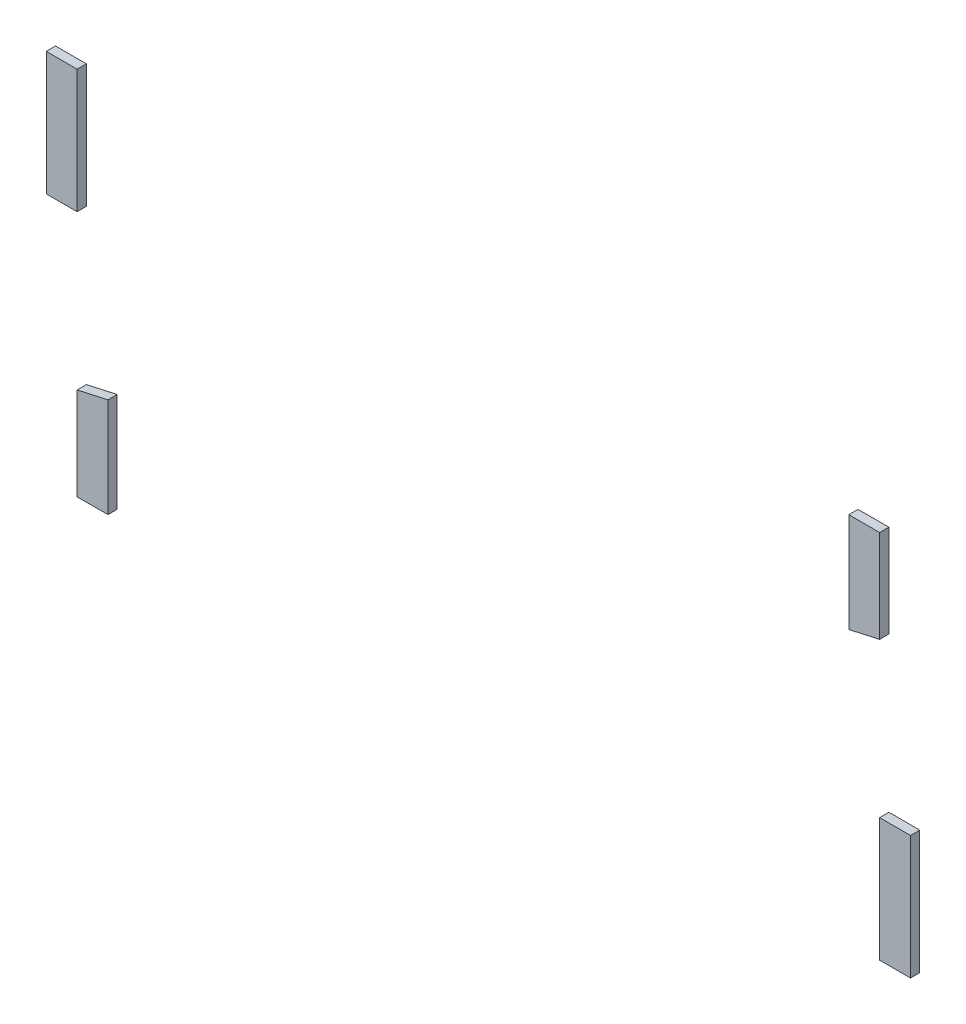
from build123d import *

# Parameters (mm, degrees)
SKETCH1_W             = 2.5
SKETCH1_H             = 10
BOSS_EXTRUDE1_DEPTH   = 0.75
BOSS_EXTRUDE1_2_DEPTH = 0.75
BOSS_EXTRUDE1_3_DEPTH = 0.75
BOSS_EXTRUDE1_4_DEPTH = 0.75


with BuildPart() as part:
    # Sketch1 → Boss-Extrude1 (new body)
    with BuildSketch(Plane.XY):
        with Locations((-33.75, 10)):
            Rectangle(SKETCH1_W, SKETCH1_H)
    extrude(amount=BOSS_EXTRUDE1_DEPTH)


with BuildPart() as body_2:
    # Sketch1 → Boss-Extrude1 2 (new body)
    with BuildSketch(Plane.XY):
        Polygon((30, 15), (32.5, 15), (32.5, 7.5), (30, 6.944444444), align=None)
    extrude(amount=BOSS_EXTRUDE1_2_DEPTH)


with BuildPart() as body_3:
    # Sketch1 → Boss-Extrude1 3 (new body)
    with BuildSketch(Plane.XY):
        Polygon((-32.5, -7.5), (-32.5, -15), (-30, -15), (-30, -6.944444444), align=None)
    extrude(amount=BOSS_EXTRUDE1_3_DEPTH)


with BuildPart() as body_4:
    # Sketch1 → Boss-Extrude1 4 (new body)
    with BuildSketch(Plane.XY):
        with Locations((33.75, -10)):
            Rectangle(SKETCH1_W, SKETCH1_H)
    extrude(amount=BOSS_EXTRUDE1_4_DEPTH)


solid = Compound([part.part, body_2.part, body_3.part, body_4.part])
